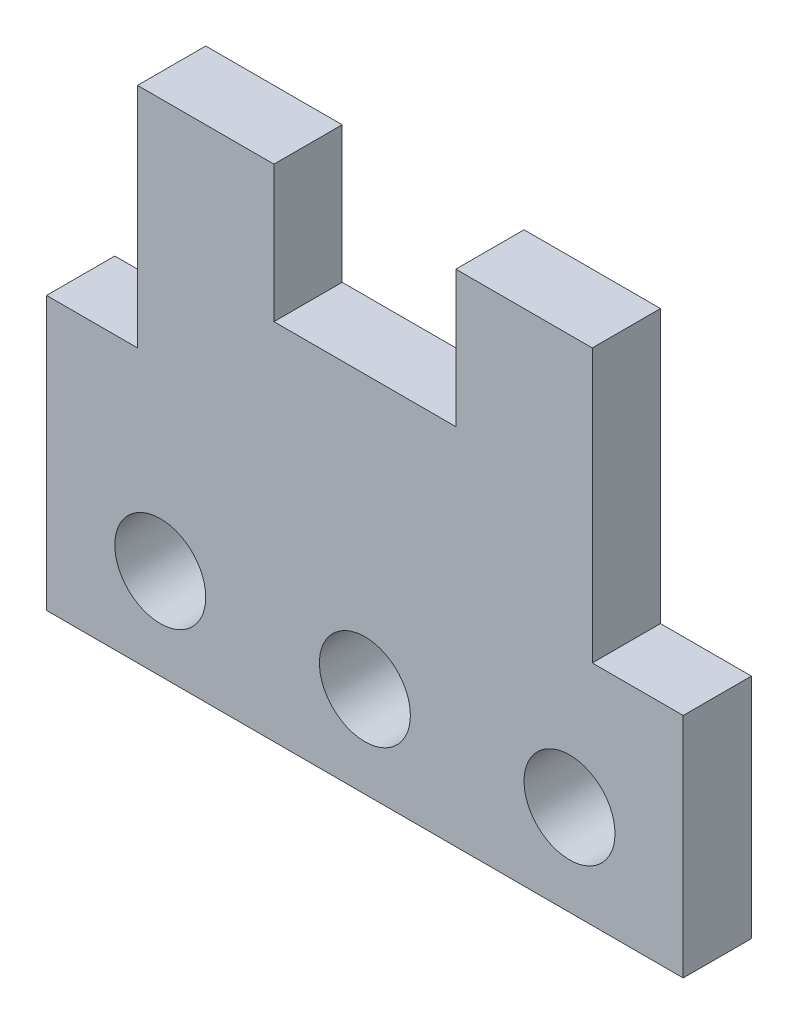
from build123d import *

# Parameters (mm, degrees)
SKETCH1_R           = 10
BOSS_EXTRUDE1_DEPTH = 15


with BuildPart() as part:
    # Sketch1 (on Front Plane) → Boss-Extrude1 (new body)
    with BuildSketch(Plane.XY):
        Polygon((-70, 19.808892587), (-70, -40.191107413), (70, -40.191107413), (70, 9.808892587), (50, 9.808892587), (50, 69.808892587), (20, 69.808892587), (20, 39.808892587), (-20, 39.808892587), (-20, 69.808892587), (-50, 69.808892587), (-50, 19.808892587), align=None)
        with Locations((-45, -20.191107413)):
            Circle(SKETCH1_R, mode=Mode.SUBTRACT)
        with Locations((0, -20.191107413)):
            Circle(SKETCH1_R, mode=Mode.SUBTRACT)
        with Locations((45, -20.191107413)):
            Circle(SKETCH1_R, mode=Mode.SUBTRACT)
    extrude(amount=BOSS_EXTRUDE1_DEPTH)


solid = part.part
